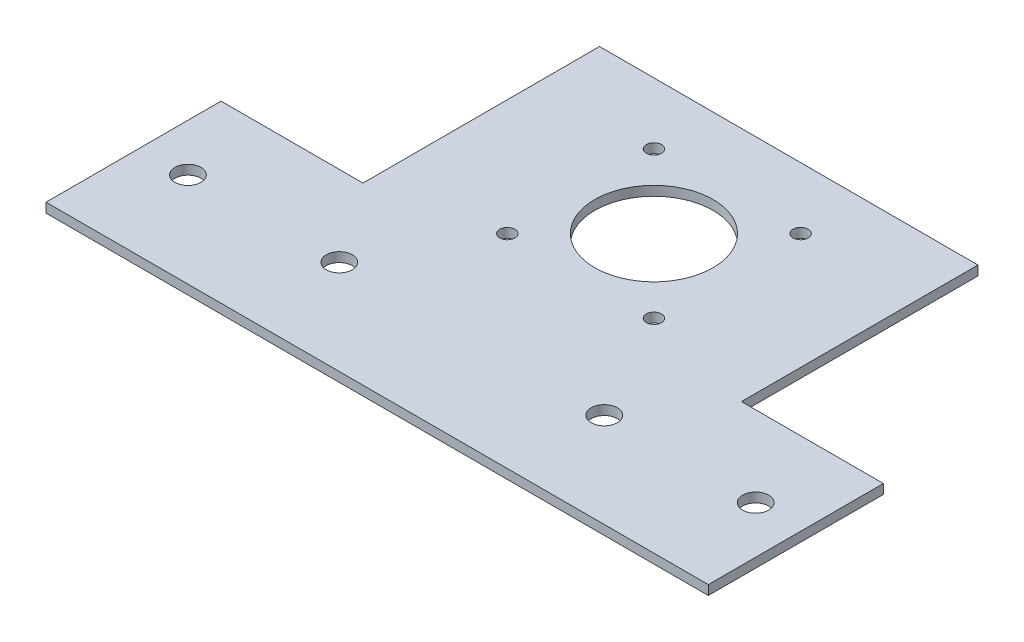
from build123d import *

# Parameters (mm, degrees)
ESQUISSE1_W             = 140
ESQUISSE1_H             = 87
ESQUISSE1_R             = 2.75
ESQUISSE1_R_2           = 1.6
ESQUISSE1_R_3           = 12.5
BOSS_EXTRU_1_DEPTH      = 2
ESQUISSE2_W             = 30
ESQUISSE2_H             = 50
ENL_V_MAT_EXTRU_1_DEPTH = 10


with BuildPart() as part:
    # Esquisse1 → Boss.-Extru.1 (new body)
    with BuildSketch(Plane(origin=(0, 0, 0), x_dir=(1, 0, 0), z_dir=(0, 1, 0))):
        Rectangle(ESQUISSE1_W, ESQUISSE1_H)
        with Locations((-60, -23.5)):
            Circle(ESQUISSE1_R, mode=Mode.SUBTRACT)
        with Locations((-28, -23.5)):
            Circle(ESQUISSE1_R, mode=Mode.SUBTRACT)
        with Locations((28, -23.5)):
            Circle(ESQUISSE1_R, mode=Mode.SUBTRACT)
        with Locations((60, -23.5)):
            Circle(ESQUISSE1_R, mode=Mode.SUBTRACT)
        with Locations((-15.5, 30.5)):
            Circle(ESQUISSE1_R_2, mode=Mode.SUBTRACT)
        with Locations((15.5, 30.5)):
            Circle(ESQUISSE1_R_2, mode=Mode.SUBTRACT)
        with Locations((15.5, -0.5)):
            Circle(ESQUISSE1_R_2, mode=Mode.SUBTRACT)
        with Locations((-15.5, -0.5)):
            Circle(ESQUISSE1_R_2, mode=Mode.SUBTRACT)
        with Locations((0, 15)):
            Circle(ESQUISSE1_R_3, mode=Mode.SUBTRACT)
    extrude(amount=BOSS_EXTRU_1_DEPTH)

    # Esquisse2 → Enlèv. mat.-Extru.1 (cut)
    with BuildSketch(Plane(origin=(0, 2, 0), x_dir=(1, 0, 0), z_dir=(0, 1, 0))):
        with Locations((-55, 18.5)):
            Rectangle(ESQUISSE2_W, ESQUISSE2_H)
        with Locations((55, 18.5)):
            Rectangle(ESQUISSE2_W, ESQUISSE2_H)
    extrude(amount=-ENL_V_MAT_EXTRU_1_DEPTH, mode=Mode.SUBTRACT)


solid = part.part
